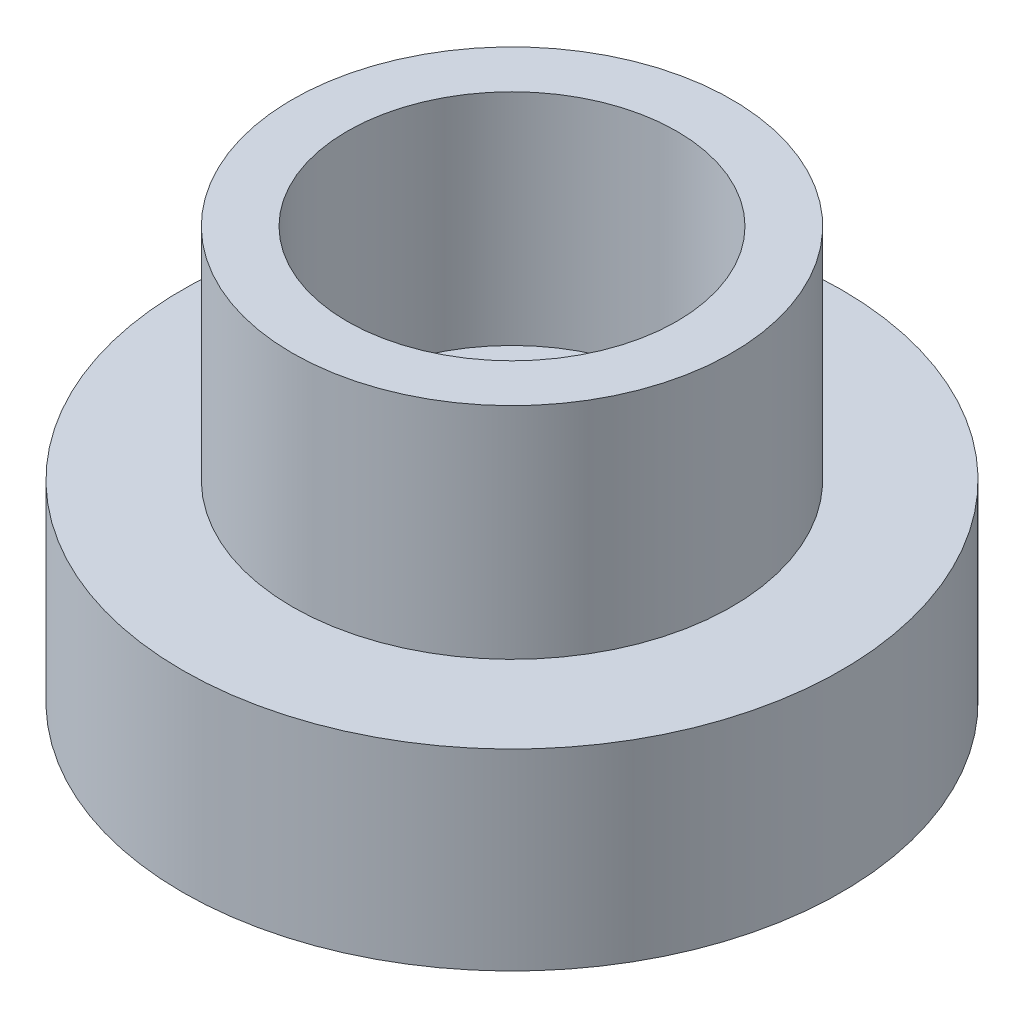
from build123d import *

# Parameters (mm, degrees)
SKETCH1_R           = 38.1
SKETCH1_R_2         = 31.115
BOSS_EXTRUDE1_DEPTH = 19.05
SKETCH2_R           = 1.64973
CUT_EXTRUDE1_DEPTH  = 12.7
SKETCH3_R           = 38.1
SKETCH3_R_2         = 12.7
BOSS_EXTRUDE2_DEPTH = 3.175
SKETCH4_R           = 25.4
SKETCH4_R_2         = 19.05
BOSS_EXTRUDE3_DEPTH = 25.4


with BuildPart() as part:
    # Sketch1 → Boss-Extrude1 (new body)
    with BuildSketch(Plane(origin=(0, 0, 0), x_dir=(1, 0, 0), z_dir=(0, 1, 0))):
        Circle(SKETCH1_R)
        Circle(SKETCH1_R_2, mode=Mode.SUBTRACT)
    extrude(amount=BOSS_EXTRUDE1_DEPTH)

    # Sketch2 → Cut-Extrude1 (cut)
    with BuildSketch(Plane.XZ):
        with Locations((0, 34.29)):
            Circle(SKETCH2_R)
        with Locations((34.29, 0)):
            Circle(SKETCH2_R)
        with Locations((0, -34.29)):
            Circle(SKETCH2_R)
        with Locations((-34.29, 0)):
            Circle(SKETCH2_R)
    extrude(amount=-CUT_EXTRUDE1_DEPTH, mode=Mode.SUBTRACT)

    # Sketch3 → Boss-Extrude2 (add)
    with BuildSketch(Plane(origin=(0, 19.05, 0), x_dir=(1, 0, 0), z_dir=(0, 1, 0))):
        Circle(SKETCH3_R)
        Circle(SKETCH3_R_2, mode=Mode.SUBTRACT)
    extrude(amount=BOSS_EXTRUDE2_DEPTH)

    # Sketch4 → Boss-Extrude3 (add)
    with BuildSketch(Plane(origin=(0, 22.225, 0), x_dir=(1, 0, 0), z_dir=(0, 1, 0))):
        Circle(SKETCH4_R)
        Circle(SKETCH4_R_2, mode=Mode.SUBTRACT)
    extrude(amount=BOSS_EXTRUDE3_DEPTH)


solid = part.part
